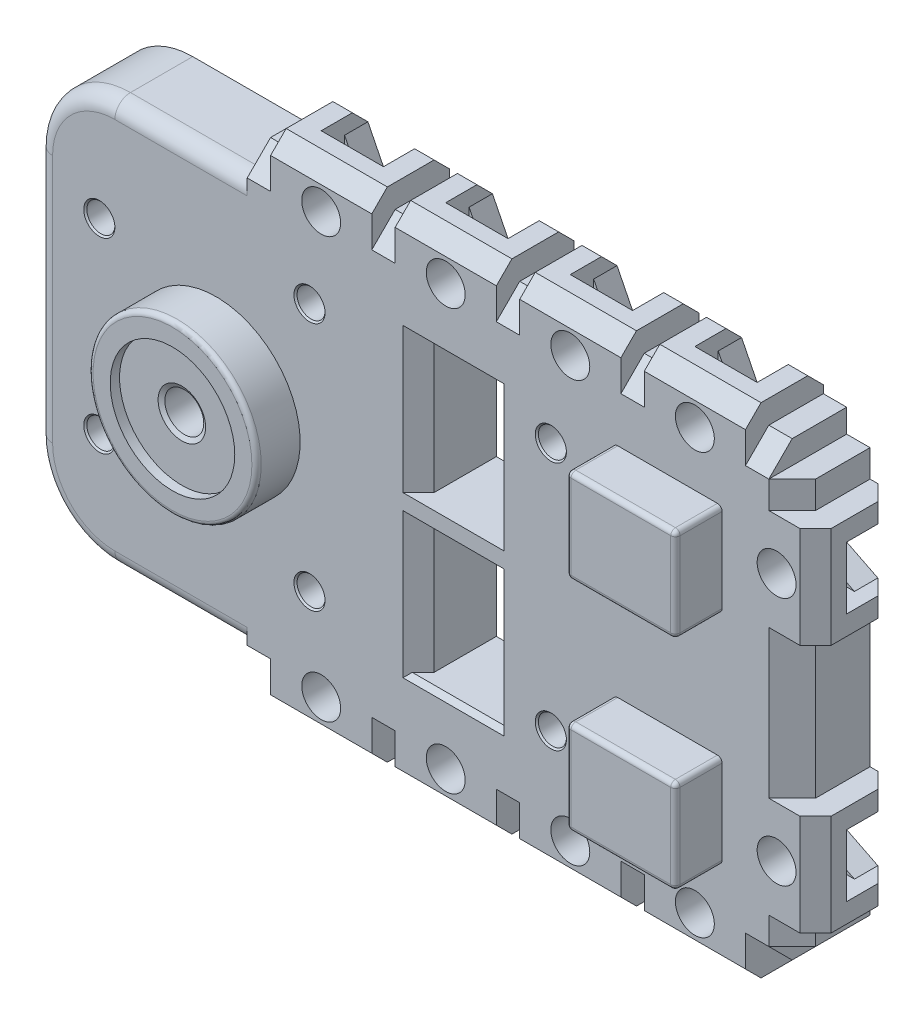
from build123d import *

# Parameters (mm, degrees)
BOSS_EXTRUDE1_DEPTH                  = 2.5
SKETCH5_W                            = 7
SKETCH5_H                            = 6
BOSS_EXTRUDE3_DEPTH                  = 3
SKETCH6_W                            = 3
SKETCH6_H                            = 4
CUT_EXTRUDE3_DEPTH                   = 1
CUT_EXTRUDE4_DEPTH                   = 1.5
CUT_EXTRUDE5_DEPTH                   = 1.5
SKETCH10_W                           = 4
SKETCH10_H                           = 3
CUT_EXTRUDE6_DEPTH                   = 1
CUT_EXTRUDE7_DEPTH                   = 1.5
CUT_EXTRUDE8_DEPTH                   = 1.5
SKETCH13_R                           = 1.25
CUT_EXTRUDE9_DEPTH                   = 2
SKETCH14_R                           = 1.25
CUT_EXTRUDE10_DEPTH                  = 2
LPATTERN1_COUNT                      = 4
LPATTERN1_PITCH                      = 8
MIRROR1_COPY_1_SKETCH_W              = 4
MIRROR1_COPY_1_SKETCH_H              = 3
MIRROR1_COPY_1_DEPTH                 = 1
MIRROR1_COPY_2_SKETCH_W              = 4
MIRROR1_COPY_2_SKETCH_H              = 3
MIRROR1_COPY_2_DEPTH                 = 1
MIRROR1_COPY_3_SKETCH_W              = 4
MIRROR1_COPY_3_SKETCH_H              = 3
MIRROR1_COPY_3_DEPTH                 = 1
MIRROR1_COPY_4_DEPTH                 = 1.5
MIRROR1_COPY_5_DEPTH                 = 1.5
MIRROR1_COPY_6_DEPTH                 = 1.5
MIRROR1_COPY_7_DEPTH                 = 1.5
MIRROR1_COPY_8_DEPTH                 = 1.5
MIRROR1_COPY_9_DEPTH                 = 1.5
MIRROR1_COPY_10_SKETCH_R             = 1.25
MIRROR1_COPY_10_DEPTH                = 2
MIRROR1_COPY_11_SKETCH_R             = 1.25
MIRROR1_COPY_11_DEPTH                = 2
MIRROR1_COPY_12_SKETCH_R             = 1.25
MIRROR1_COPY_12_DEPTH                = 2
FILLET1_R                            = 5
SKETCH2_W                            = 4.5
SKETCH2_H                            = 9
CUT_EXTRUDE1_DEPTH                   = 6
SKETCH3_R                            = 5.4
BOSS_EXTRUDE4_DEPTH                  = 2.8
SKETCH17_R                           = 4
CUT_EXTRUDE13_DEPTH                  = 0.6
F_1_6_1_6_DIAMETER_HOLE1_D           = 1.6
F_1_6_1_6_DIAMETER_HOLE1_DEPTH       = 4.5
F_1_6_1_6_DIAMETER_HOLE1_CSINK_D     = 1.8
F_1_6_1_6_DIAMETER_HOLE1_CSINK_ANGLE = 120
F_1_6_1_6_DIAMETER_HOLE1_TIP         = 0.480688495
M3_TAPPED_HOLE1_D                    = 2.5
M3_TAPPED_HOLE1_CSINK_D              = 3.05
M3_TAPPED_HOLE1_CSINK_ANGLE          = 120
F_1_8_1_8_DIAMETER_HOLE1_D           = 1.8
F_1_8_1_8_DIAMETER_HOLE1_CSINK_D     = 2
F_1_8_1_8_DIAMETER_HOLE1_CSINK_ANGLE = 90
FILLET2_R                            = 1
CHAMFER1_SIZE                        = 1
CHAMFER2_SIZE                        = 1.5
CHAMFER3_SIZE                        = 1
CHAMFER4_SIZE                        = 0.3
FILLET3_R                            = 0.3


with BuildPart() as part:
    # Sketch1 → Boss-Extrude1 (new body, symmetric)
    with BuildSketch(Plane.XY):
        Polygon((37, -13), (35.5, -13), (35.5, -14.5), (34, -14.5), (34, -16), (27.5, -16), (27.5, -14.5), (26, -14.5), (26, -16), (19.5, -16), (19.5, -14.5), (18, -14.5), (18, -16), (11.5, -16), (11.5, -14.5), (10, -14.5), (10, -16), (3.5, -16), (3.5, -14.5), (2, -14.5), (2, -13), (-11.5, -13), (-11.5, 13), (2, 13), (2, 14.5), (3.5, 14.5), (3.5, 16), (10, 16), (10, 14.5), (11.5, 14.5), (11.5, 16), (18, 16), (18, 14.5), (19.5, 14.5), (19.5, 16), (26, 16), (26, 14.5), (27.5, 14.5), (27.5, 16), (34, 16), (34, 14.5), (35.5, 14.5), (35.5, 13), (37, 13), (37, 11.25), (38.5, 11.25), (38.5, 4.75), (37, 4.75), (37, -4.75), (38.5, -4.75), (38.5, -11.25), (37, -11.25), align=None)
    extrude(amount=BOSS_EXTRUDE1_DEPTH, both=True)

    # Sketch5 → Boss-Extrude3 (add)
    with BuildSketch(Plane.XY.offset(2.5)):
        with Locations((29, 7)):
            Rectangle(SKETCH5_W, SKETCH5_H)
        with Locations((29, -7)):
            Rectangle(SKETCH5_W, SKETCH5_H)
    extrude(amount=BOSS_EXTRUDE3_DEPTH)

    # Sketch6 → Cut-Extrude3 (cut)
    with BuildSketch(Plane(origin=(38.5, 0, 0), x_dir=(0, 0, -1), z_dir=(1, 0, 0))):
        with Locations((1, 8)):
            Rectangle(SKETCH6_W, SKETCH6_H)
    cut_extrude3 = extrude(amount=-CUT_EXTRUDE3_DEPTH, mode=Mode.SUBTRACT)

    # Sketch7 → Cut-Extrude4 (cut)
    with BuildSketch(Plane(origin=(0, 0, 0.5), x_dir=(-1, 0, 0), z_dir=(0, 0, -1))):
        Polygon((-37.154700538, 6), (-34.845299462, 6), (-33.690598923, 8), (-34.845299462, 10), (-37.154700538, 10), (-38.5, 10), (-38.5, 6), align=None)
    cut_extrude4 = extrude(amount=CUT_EXTRUDE4_DEPTH, mode=Mode.SUBTRACT)

    # Sketch8 → Cut-Extrude5 (cut)
    with BuildSketch(Plane(origin=(0, 0, -2.5), x_dir=(-1, 0, 0), z_dir=(0, 0, -1))):
        Polygon((-37.5, 10), (-35.5, 9), (-35.5, 7), (-37.5, 6), align=None)
    cut_extrude5 = extrude(amount=-CUT_EXTRUDE5_DEPTH, mode=Mode.SUBTRACT)

    # Sketch10 → Cut-Extrude6 (cut)
    with BuildSketch(Plane(origin=(0, 16, 0), x_dir=(1, 0, 0), z_dir=(0, 1, 0))):
        with Locations((30.75, 1)):
            Rectangle(SKETCH10_W, SKETCH10_H)
    cut_extrude6 = extrude(amount=-CUT_EXTRUDE6_DEPTH, mode=Mode.SUBTRACT)

    # Sketch11 → Cut-Extrude7 (cut)
    with BuildSketch(Plane(origin=(0, 0, 0.5), x_dir=(-1, 0, 0), z_dir=(0, 0, -1))):
        Polygon((-32.75, 14.654700538), (-32.75, 12.345299462), (-30.75, 11.190598923), (-28.75, 12.345299462), (-28.75, 14.654700538), (-28.75, 16), (-32.75, 16), align=None)
    cut_extrude7 = extrude(amount=CUT_EXTRUDE7_DEPTH, mode=Mode.SUBTRACT)

    # Sketch12 → Cut-Extrude8 (cut)
    with BuildSketch(Plane(origin=(0, 0, -2.5), x_dir=(-1, 0, 0), z_dir=(0, 0, -1))):
        Polygon((-28.75, 15), (-29.75, 13), (-31.75, 13), (-32.75, 15), align=None)
    cut_extrude8 = extrude(amount=-CUT_EXTRUDE8_DEPTH, mode=Mode.SUBTRACT)

    # Sketch13 → Cut-Extrude9 (cut)
    with BuildSketch(Plane.XY.offset(2.5)):
        with Locations((36, 8)):
            Circle(SKETCH13_R)
    cut_extrude9 = extrude(amount=-CUT_EXTRUDE9_DEPTH, mode=Mode.SUBTRACT)

    # Sketch14 → Cut-Extrude10 (cut)
    with BuildSketch(Plane.XY.offset(2.5)):
        with Locations((30.75, 13.5)):
            Circle(SKETCH14_R)
    cut_extrude10 = extrude(amount=-CUT_EXTRUDE10_DEPTH, mode=Mode.SUBTRACT)

    # LPattern1: Cut-Extrude6, Cut-Extrude7, Cut-Extrude8, Cut-Extrude10 ×4
    with Locations(*[(-i * LPATTERN1_PITCH, 0, 0) for i in range(1, LPATTERN1_COUNT)]):
        add(cut_extrude6, mode=Mode.SUBTRACT)
        add(cut_extrude7, mode=Mode.SUBTRACT)
        add(cut_extrude8, mode=Mode.SUBTRACT)
        add(cut_extrude10, mode=Mode.SUBTRACT)

    # Mirror1: Cut-Extrude10, Cut-Extrude9, Cut-Extrude8, Cut-Extrude7, Cut-Extrude6, Cut-Extrude5, Cut-Extrude4, Cut-Extrude3 across plane
    add(cut_extrude10.mirror(Plane.ZX), mode=Mode.SUBTRACT)
    add(cut_extrude9.mirror(Plane.ZX), mode=Mode.SUBTRACT)
    add(cut_extrude8.mirror(Plane.ZX), mode=Mode.SUBTRACT)
    add(cut_extrude7.mirror(Plane.ZX), mode=Mode.SUBTRACT)
    add(cut_extrude6.mirror(Plane.ZX), mode=Mode.SUBTRACT)
    add(cut_extrude5.mirror(Plane.ZX), mode=Mode.SUBTRACT)
    add(cut_extrude4.mirror(Plane.ZX), mode=Mode.SUBTRACT)
    add(cut_extrude3.mirror(Plane.ZX), mode=Mode.SUBTRACT)

    # Mirror1 copy 1 sketch → Mirror1 copy 1 (cut)
    with BuildSketch(Plane(origin=(-8, -16, 0), x_dir=(1, 0, 0), z_dir=(0, -1, 0))):
        with Locations((30.75, -1)):
            Rectangle(MIRROR1_COPY_1_SKETCH_W, MIRROR1_COPY_1_SKETCH_H)
    extrude(amount=-MIRROR1_COPY_1_DEPTH, mode=Mode.SUBTRACT)

    # Mirror1 copy 2 sketch → Mirror1 copy 2 (cut)
    with BuildSketch(Plane(origin=(-16, -16, 0), x_dir=(1, 0, 0), z_dir=(0, -1, 0))):
        with Locations((30.75, -1)):
            Rectangle(MIRROR1_COPY_2_SKETCH_W, MIRROR1_COPY_2_SKETCH_H)
    extrude(amount=-MIRROR1_COPY_2_DEPTH, mode=Mode.SUBTRACT)

    # Mirror1 copy 3 sketch → Mirror1 copy 3 (cut)
    with BuildSketch(Plane(origin=(-24, -16, 0), x_dir=(1, 0, 0), z_dir=(0, -1, 0))):
        with Locations((30.75, -1)):
            Rectangle(MIRROR1_COPY_3_SKETCH_W, MIRROR1_COPY_3_SKETCH_H)
    extrude(amount=-MIRROR1_COPY_3_DEPTH, mode=Mode.SUBTRACT)

    # Mirror1 copy 4 sketch → Mirror1 copy 4 (cut)
    with BuildSketch(Plane(origin=(-8, 0, 0.5), x_dir=(-1, 0, 0), z_dir=(0, 0, -1))):
        Polygon((-32.75, -14.654700538), (-32.75, -12.345299462), (-30.75, -11.190598923), (-28.75, -12.345299462), (-28.75, -14.654700538), (-28.75, -16), (-32.75, -16), align=None)
    extrude(amount=MIRROR1_COPY_4_DEPTH, mode=Mode.SUBTRACT)

    # Mirror1 copy 5 sketch → Mirror1 copy 5 (cut)
    with BuildSketch(Plane(origin=(-16, 0, 0.5), x_dir=(-1, 0, 0), z_dir=(0, 0, -1))):
        Polygon((-32.75, -14.654700538), (-32.75, -12.345299462), (-30.75, -11.190598923), (-28.75, -12.345299462), (-28.75, -14.654700538), (-28.75, -16), (-32.75, -16), align=None)
    extrude(amount=MIRROR1_COPY_5_DEPTH, mode=Mode.SUBTRACT)

    # Mirror1 copy 6 sketch → Mirror1 copy 6 (cut)
    with BuildSketch(Plane(origin=(-24, 0, 0.5), x_dir=(-1, 0, 0), z_dir=(0, 0, -1))):
        Polygon((-32.75, -14.654700538), (-32.75, -12.345299462), (-30.75, -11.190598923), (-28.75, -12.345299462), (-28.75, -14.654700538), (-28.75, -16), (-32.75, -16), align=None)
    extrude(amount=MIRROR1_COPY_6_DEPTH, mode=Mode.SUBTRACT)

    # Mirror1 copy 7 sketch → Mirror1 copy 7 (cut)
    with BuildSketch(Plane(origin=(-8, 0, -2.5), x_dir=(-1, 0, 0), z_dir=(0, 0, -1))):
        Polygon((-28.75, -15), (-29.75, -13), (-31.75, -13), (-32.75, -15), align=None)
    extrude(amount=-MIRROR1_COPY_7_DEPTH, mode=Mode.SUBTRACT)

    # Mirror1 copy 8 sketch → Mirror1 copy 8 (cut)
    with BuildSketch(Plane(origin=(-16, 0, -2.5), x_dir=(-1, 0, 0), z_dir=(0, 0, -1))):
        Polygon((-28.75, -15), (-29.75, -13), (-31.75, -13), (-32.75, -15), align=None)
    extrude(amount=-MIRROR1_COPY_8_DEPTH, mode=Mode.SUBTRACT)

    # Mirror1 copy 9 sketch → Mirror1 copy 9 (cut)
    with BuildSketch(Plane(origin=(-24, 0, -2.5), x_dir=(-1, 0, 0), z_dir=(0, 0, -1))):
        Polygon((-28.75, -15), (-29.75, -13), (-31.75, -13), (-32.75, -15), align=None)
    extrude(amount=-MIRROR1_COPY_9_DEPTH, mode=Mode.SUBTRACT)

    # Mirror1 copy 10 sketch → Mirror1 copy 10 (cut)
    with BuildSketch(Plane(origin=(-8, 0, 2.5), x_dir=(1, 0, 0), z_dir=(0, 0, 1))):
        with Locations((30.75, -13.5)):
            Circle(MIRROR1_COPY_10_SKETCH_R)
    extrude(amount=-MIRROR1_COPY_10_DEPTH, mode=Mode.SUBTRACT)

    # Mirror1 copy 11 sketch → Mirror1 copy 11 (cut)
    with BuildSketch(Plane(origin=(-16, 0, 2.5), x_dir=(1, 0, 0), z_dir=(0, 0, 1))):
        with Locations((30.75, -13.5)):
            Circle(MIRROR1_COPY_11_SKETCH_R)
    extrude(amount=-MIRROR1_COPY_11_DEPTH, mode=Mode.SUBTRACT)

    # Mirror1 copy 12 sketch → Mirror1 copy 12 (cut)
    with BuildSketch(Plane(origin=(-24, 0, 2.5), x_dir=(1, 0, 0), z_dir=(0, 0, 1))):
        with Locations((30.75, -13.5)):
            Circle(MIRROR1_COPY_12_SKETCH_R)
    extrude(amount=-MIRROR1_COPY_12_DEPTH, mode=Mode.SUBTRACT)

    # Fillet1
    fillet1_edges = [part.edges().sort_by_distance(p)[0] for p in [
        (-11.5, -13, 0),
        (-11.5, 13, 0),
    ]]
    fillet(fillet1_edges, radius=FILLET1_R)

    # Sketch2 → Cut-Extrude1 (cut, through all)
    with BuildSketch(Plane.XY.offset(2.5)):
        with Locations((15.25, 5)):
            Rectangle(SKETCH2_W, SKETCH2_H)
        with Locations((15.25, -5)):
            Rectangle(SKETCH2_W, SKETCH2_H)
    extrude(amount=-CUT_EXTRUDE1_DEPTH, mode=Mode.SUBTRACT)

    # Sketch3 → Boss-Extrude4 (add)
    with BuildSketch(Plane.XY.offset(2.5)):
        Circle(SKETCH3_R)
    extrude(amount=BOSS_EXTRUDE4_DEPTH)

    # Sketch17 → Cut-Extrude13 (cut)
    with BuildSketch(Plane.XY.offset(5.3)):
        Circle(SKETCH17_R)
    extrude(amount=-CUT_EXTRUDE13_DEPTH, mode=Mode.SUBTRACT)

    # Ø1.6 (1.6) Diameter Hole1
    with Locations(Plane(origin=(0, 0, -2.5), x_dir=(-1, 0, 0), z_dir=(0, 0, -1))):
        with Locations((-33, 10.4), (-33, -10.4), (9, 9.25), (9, -9.25)):
            CounterSinkHole(F_1_6_1_6_DIAMETER_HOLE1_D / 2, F_1_6_1_6_DIAMETER_HOLE1_CSINK_D / 2, depth=F_1_6_1_6_DIAMETER_HOLE1_DEPTH, counter_sink_angle=F_1_6_1_6_DIAMETER_HOLE1_CSINK_ANGLE)
            with Locations((0, 0, -(F_1_6_1_6_DIAMETER_HOLE1_DEPTH + F_1_6_1_6_DIAMETER_HOLE1_TIP / 2))):  # 118° drill point
                Cone(0, F_1_6_1_6_DIAMETER_HOLE1_D / 2, F_1_6_1_6_DIAMETER_HOLE1_TIP, mode=Mode.SUBTRACT)

    # M3 Tapped Hole1 (through all)
    with Locations(Plane.XY.offset(4.7)):
        with Locations((0, 0)):
            CounterSinkHole(M3_TAPPED_HOLE1_D / 2, M3_TAPPED_HOLE1_CSINK_D / 2, counter_sink_angle=M3_TAPPED_HOLE1_CSINK_ANGLE)

    # Ø1.8 (1.8) Diameter Hole1 (through all)
    with Locations(Plane.XY.offset(2.5)):
        with Locations((6, 8), (21.5, 8), (-7.5, 6), (21.5, -8), (6, -8), (-7.5, -6)):
            CounterSinkHole(F_1_8_1_8_DIAMETER_HOLE1_D / 2, F_1_8_1_8_DIAMETER_HOLE1_CSINK_D / 2, counter_sink_angle=F_1_8_1_8_DIAMETER_HOLE1_CSINK_ANGLE)

    # Fillet2
    fillet2_edges = [part.edges().sort_by_distance(p)[0] for p in [
        (-2.25, 13, 2.5),
        (-2.25, -13, 2.5),
        (-11.5, 0, 2.5),
        (-10.035533906, 11.535533906, 2.5),
        (-10.035533906, -11.535533906, 2.5),
    ]]
    fillet(fillet2_edges, radius=FILLET2_R)

    # Chamfer1
    chamfer1_edges = [part.edges().sort_by_distance(p)[0] for p in [
        (4.125, -16, -2.5),
        (9.375, -16, -2.5),
        (12.125, -16, -2.5),
        (17.375, -16, -2.5),
        (20.125, -16, -2.5),
        (25.375, -16, -2.5),
        (28.125, -16, -2.5),
        (33.375, -16, -2.5),
        (4.125, 16, -2.5),
        (9.375, 16, -2.5),
        (12.125, 16, -2.5),
        (17.375, 16, -2.5),
        (20.125, 16, -2.5),
        (25.375, 16, -2.5),
        (28.125, 16, -2.5),
        (33.375, 16, -2.5),
        (38.5, -10.625, -2.5),
        (38.5, -5.375, -2.5),
        (38.5, 5.375, -2.5),
        (38.5, 10.625, -2.5),
        (6.75, 16, 2.5),
        (14.75, 16, 2.5),
        (22.75, 16, 2.5),
        (30.75, 16, 2.5),
        (38.5, 8, 2.5),
        (38.5, -8, 2.5),
        (30.75, -16, 2.5),
        (22.75, -16, 2.5),
        (14.75, -16, 2.5),
        (6.75, -16, 2.5),
    ]]
    chamfer(chamfer1_edges, length=CHAMFER1_SIZE)

    # Chamfer2
    chamfer2_edges = [part.edges().sort_by_distance(p)[0] for p in [
        (34.75, 14.5, 2.5),
        (26.75, 14.5, 2.5),
        (18.75, 14.5, 2.5),
        (10.75, 14.5, 2.5),
        (2.75, 14.5, 2.5),
        (2.75, -14.5, 2.5),
        (10.75, -14.5, 2.5),
        (18.75, -14.5, 2.5),
        (26.75, -14.5, 2.5),
        (34.75, -14.5, 2.5),
        (37, -12.125, 2.5),
        (37, 0, 2.5),
        (37, 12.125, 2.5),
    ]]
    chamfer(chamfer2_edges, length=CHAMFER2_SIZE)

    # Chamfer3
    chamfer3_edges = [part.edges().sort_by_distance(p)[0] for p in [
        (17.5, 5, 2.5),
        (13, 5, 2.5),
        (17.5, -5, 2.5),
        (13, -5, 2.5),
    ]]
    chamfer(chamfer3_edges, length=CHAMFER3_SIZE)

    # Chamfer4
    chamfer4_edges = [part.edges().sort_by_distance(p)[0] for p in [
        (15.25, 9.5, 2.5),
        (15.25, -9.5, 2.5),
    ]]
    chamfer(chamfer4_edges, length=CHAMFER4_SIZE)

    # Fillet3
    fillet3_edges = [part.edges().sort_by_distance(p)[0] for p in [
        (32.5, 4, 4),
        (32.5, 10, 4),
        (25.5, 10, 4),
        (25.5, 4, 4),
        (32.5, 7, 5.5),
        (29, 10, 5.5),
        (25.5, 7, 5.5),
        (29, 4, 5.5),
        (25.5, -10, 4),
        (32.5, -10, 4),
        (32.5, -4, 4),
        (25.5, -4, 4),
        (29, -10, 5.5),
        (32.5, -7, 5.5),
        (29, -4, 5.5),
        (25.5, -7, 5.5),
        (-5.4, 0, 5.3),
    ]]
    fillet(fillet3_edges, radius=FILLET3_R)


solid = part.part
